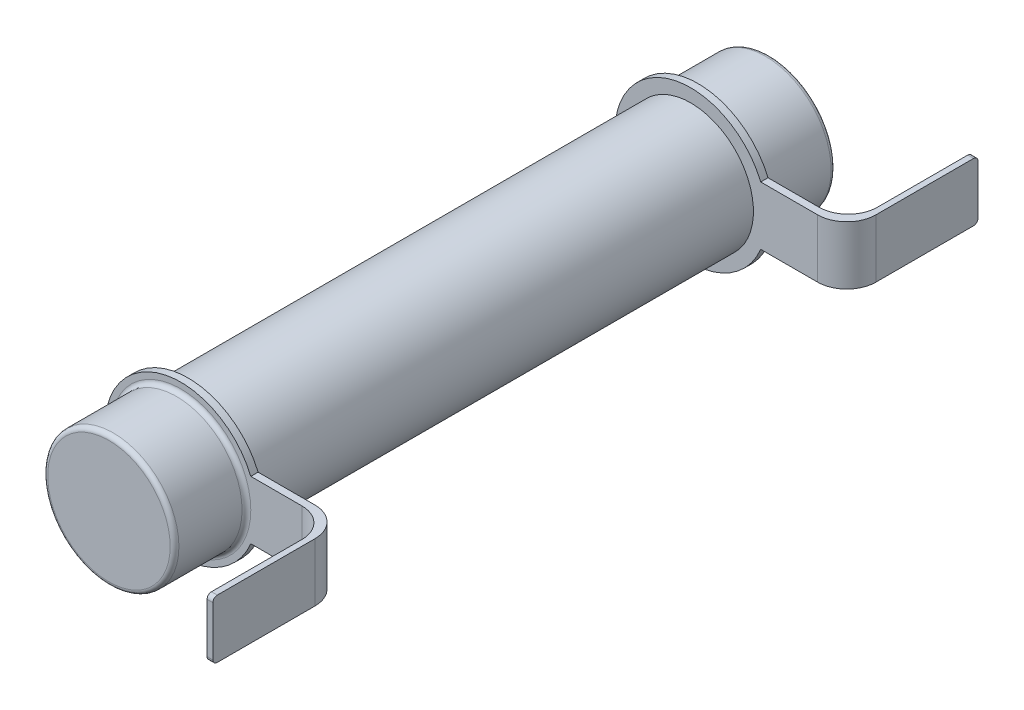
from build123d import *

# Parameters (mm, degrees)
SKETCH1_R           = 4.3
BOSS_EXTRUDE1_DEPTH = 22.665
SKETCH2_R           = 4.5
SKETCH2_R_2         = 4.3
BOSS_EXTRUDE2_DEPTH = 5.43
SKETCH3_R           = 5.2
SKETCH3_R_2         = 4.5
BOSS_EXTRUDE3_DEPTH = 0.5
SKETCH5_W           = 9
SKETCH5_H           = 4
BOSS_EXTRUDE4_DEPTH = 0.4
SKETCH6_W           = 0.5
SKETCH6_H           = 4
BOSS_EXTRUDE5_DEPTH = 5.5
SKETCH7_W           = 9
SKETCH7_H           = 4
BOSS_EXTRUDE6_DEPTH = 0.4
SKETCH8_W           = 0.5
SKETCH8_H           = 4
BOSS_EXTRUDE7_DEPTH = 5.5
FILLET2_R           = 2
FILLET3_R           = 0.3


with BuildPart() as part:
    # Sketch1 → Boss-Extrude1 (new body, symmetric)
    with BuildSketch(Plane.XY):
        Circle(SKETCH1_R)
    extrude(amount=BOSS_EXTRUDE1_DEPTH, both=True)

    # Sketch2 → Boss-Extrude2 (add)
    with BuildSketch(Plane.XY.offset(22.665)):
        Circle(SKETCH2_R)
        Circle(SKETCH2_R_2, mode=Mode.SUBTRACT)
    boss_extrude2 = extrude(amount=-BOSS_EXTRUDE2_DEPTH)

    # Sketch3 → Boss-Extrude3 (add)
    with BuildSketch(Plane.XY.offset(17.235)):
        Circle(SKETCH3_R)
        Circle(SKETCH3_R_2, mode=Mode.SUBTRACT)
    boss_extrude3 = extrude(amount=BOSS_EXTRUDE3_DEPTH)

    # Mirror1: Boss-Extrude2, Boss-Extrude3 across plane
    add(boss_extrude2.mirror(Plane.XY))
    add(boss_extrude3.mirror(Plane.XY))



with BuildPart() as body_2:
    # Sketch5 → Boss-Extrude4 (new body)
    with BuildSketch(Plane(origin=(10.7, 0, 0), x_dir=(0, 0, -1), z_dir=(1, 0, 0))):
        with Locations((21.735, 0)):
            Rectangle(SKETCH5_W, SKETCH5_H)
    extrude(amount=-BOSS_EXTRUDE4_DEPTH)


with BuildPart() as part_1:
    add(part.part)

    add(body_2.part)  # Boss-Extrude5 merges body 2
    # Sketch6 → Boss-Extrude5 (add)
    with BuildSketch(Plane.ZY.offset(-10.3)):
        with Locations((-17.485, 0)):
            Rectangle(SKETCH6_W, SKETCH6_H)
    extrude(amount=BOSS_EXTRUDE5_DEPTH)



with BuildPart() as body_2_2:
    # Sketch7 → Boss-Extrude6 (new body)
    with BuildSketch(Plane(origin=(10.7, 0, 0), x_dir=(0, 0, -1), z_dir=(1, 0, 0))):
        with Locations((-21.735, 0)):
            Rectangle(SKETCH7_W, SKETCH7_H)
    extrude(amount=-BOSS_EXTRUDE6_DEPTH)


with BuildPart() as part_2:
    add(part_1.part)

    add(body_2_2.part)  # Boss-Extrude7 merges body 2 2
    # Sketch8 → Boss-Extrude7 (add)
    with BuildSketch(Plane.ZY.offset(-10.3)):
        with Locations((17.485, 0)):
            Rectangle(SKETCH8_W, SKETCH8_H)
    extrude(amount=BOSS_EXTRUDE7_DEPTH)

    # Fillet2
    fillet2_edges = [part_2.edges().sort_by_distance(p)[0] for p in [
        (10.3, 0, -17.735),
        (10.7, 0, -17.235),
        (10.3, 0, 17.735),
        (10.7, 0, 17.235),
    ]]
    fillet(fillet2_edges, radius=FILLET2_R)

    # Fillet3
    fillet3_edges = [part_2.edges().sort_by_distance(p)[0] for p in [
        (-4.5, 0, 17.735),
        (-4.5, 0, -22.665),
        (10.5, 2, -26.235),
        (10.5, -2, -26.235),
        (10.5, -2, 26.235),
        (10.5, 2, 26.235),
        (-4.5, 0, 22.665),
    ]]
    fillet(fillet3_edges, radius=FILLET3_R)


solid = part_2.part
